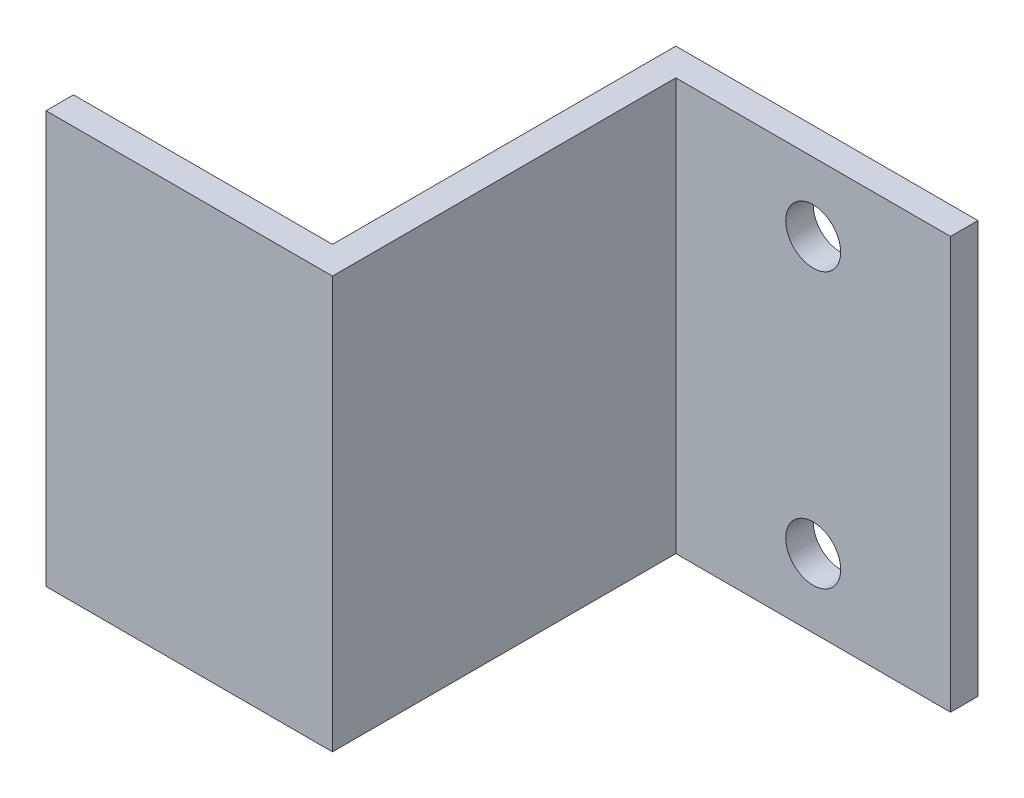
from build123d import *

# Parameters (mm, degrees)
EXTRUDE_1_DEPTH     = 30
SKETCH_2_R          = 2
CUT_EXTRUDE_1_DEPTH = 28


with BuildPart() as part:
    # Эскиз1 → Бобышка-Вытянуть1 (new body)
    with BuildSketch(Plane(origin=(0, 0, 0), x_dir=(1, 0, 0), z_dir=(0, 1, 0))):
        Polygon((0, 0), (-20.856344092, 0), (-20.856344092, 2), (-2, 2), (-2, 27), (20, 27), (20, 25), (0, 25), align=None)
    extrude(amount=EXTRUDE_1_DEPTH)

    # Эскиз2 → Вырез-Вытянуть1 (cut, through all)
    with BuildSketch(Plane(origin=(0, 0, -27), x_dir=(-1, 0, 0), z_dir=(0, 0, -1))):
        with Locations((-10, 25)):
            Circle(SKETCH_2_R)
        with Locations((-10, 5)):
            Circle(SKETCH_2_R)
    extrude(amount=-CUT_EXTRUDE_1_DEPTH, mode=Mode.SUBTRACT)


solid = part.part
